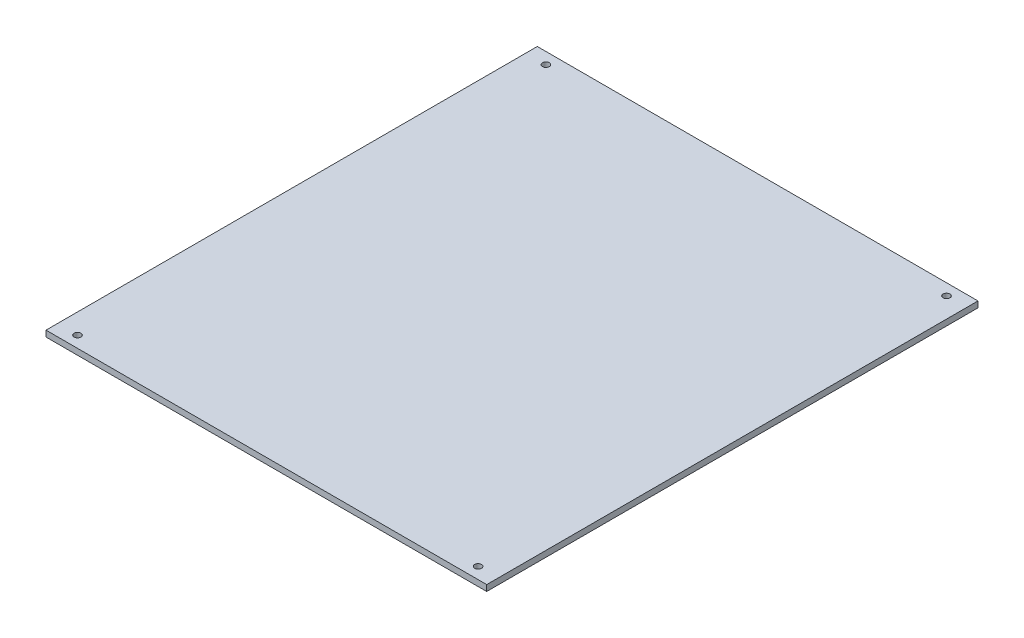
from build123d import *

# Parameters (mm, degrees)
ESQUISSE1_W        = 219.77
ESQUISSE1_H        = 3
EXTRU_MINCE1_DEPTH = 245
D_GAGEMENT_M31_D   = 3.4


with BuildPart() as part:
    # Esquisse1 → Extru.-Mince1 (new body)
    with BuildSketch(Plane.XY):
        with Locations((69.60068085, -1.5)):
            Rectangle(ESQUISSE1_W, ESQUISSE1_H)
    extrude(amount=EXTRU_MINCE1_DEPTH)

    # Dégagement M31 (through all)
    with Locations(Plane(origin=(0, 0, 0), x_dir=(-1, 0, 0), z_dir=(0, 1, 0))):
        with Locations((30.28431915, 5.7), (-169.48568085, 5.7), (30.28431915, 239.3), (-169.48568085, 239.3)):
            Hole(D_GAGEMENT_M31_D / 2)


solid = part.part
